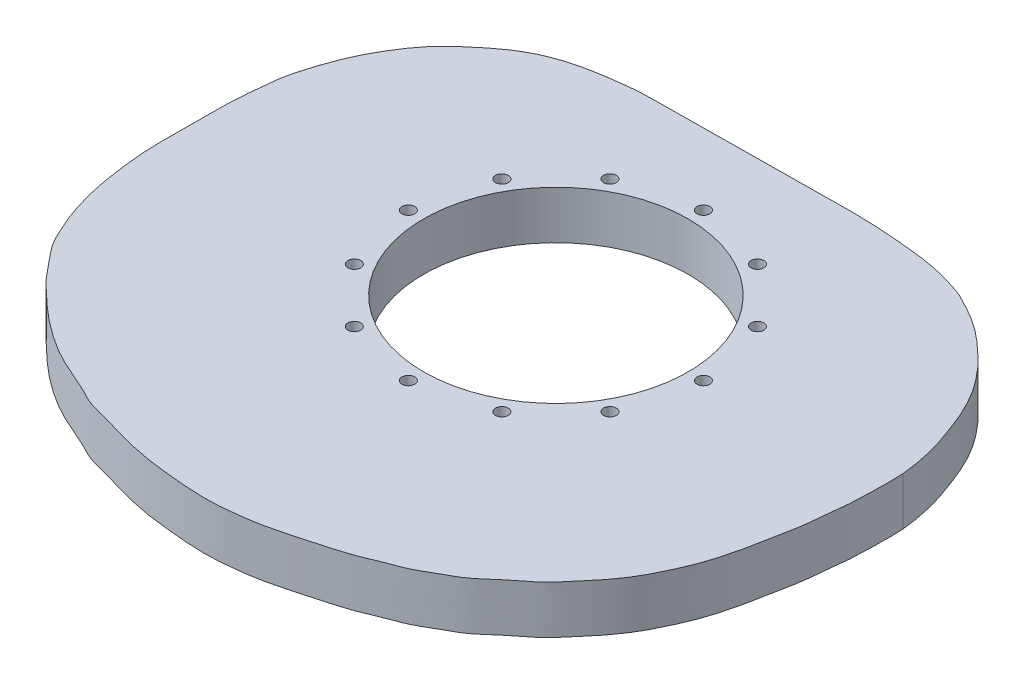
from build123d import *

# Parameters (mm, degrees)
SKETCH1_R               = 70.0278
BOSS_EXTRUDE1_DEPTH     = 25.4
F_1_4_CLEARANCE_HOLE2_D = 6.7564


with BuildPart() as part:
    # Sketch1 → Boss-Extrude1 (new body)
    with BuildSketch(Plane.XZ.offset(5)):
        with BuildLine():
            add(Edge.make_bspline(
                [(-380.049242402, 11.384506124), (-380.351727709, 7.622790631), (-381.694235545, -0.755231418), (-384.446209251, -11.663714484), (-388.103085236, -21.392143302), (-391.925650274, -31.575766127), (-398.295486923, -43.924651464), (-407.128882868, -55.651987185), (-416.38233598, -64.721478176), (-428.702675028, -75.720010967), (-441.765278826, -82.662991669), (-448.736085978, -86.474565006), (-459.378159259, -89.383248937), (-468.639960146, -91.8901143), (-483.883064645, -93.531241417), (-505.293765442, -95.360493014), (-537.935613256, -94.80996853), (-620.863987688, -94.064878486), (-625.28981964, -93.74269195), (-632.616728819, -93.108667889), (-643.969557151, -91.505035169), (-654.698440304, -89.313581428), (-665.553686296, -85.820433064), (-677.5449018, -79.679626513), (-689.821764124, -69.789276702), (-700.818947164, -59.846392143), (-709.719423576, -47.179017), (-717.454447417, -32.860897599), (-722.916833642, -16.936482122), (-725.870843695, -5.469698769), (-726.432591043, 2.747731753), (-728.061402677, 15.952356205), (-728.016636304, 29.622005318), (-728.183208156, 51.378488644), (-728.21049183, 66.165802061), (-725.016148135, 91.652991888), (-719.307424347, 111.760000031), (-715.0325054, 120.938944975), (-713.402971141, 124.355557991)],
                knots=[0.50544859, 0.50544859, 0.50544859, 0.50544859, 0.517878892, 0.529901202, 0.541289027, 0.552999913, 0.566304447, 0.57990339, 0.592750982, 0.607327706, 0.620921089, 0.630996152, 0.642558345, 0.653666263, 0.667424603, 0.6832709, 0.705284101, 0.73716196, 0.744619627, 0.753696597, 0.765929643, 0.777787395, 0.789712766, 0.802766477, 0.816920196, 0.830645044, 0.844557861, 0.859020432, 0.873719976, 0.885805087, 0.895975767, 0.908692411, 0.922195793, 0.938566323, 0.952559431, 0.970498516, 0.987057969, 1, 1, 1, 1], degree=3))
            add(Edge.make_bspline(
                [(-713.402971141, 124.355557991), (-712.082084168, 127.125036205), (-709.617350154, 132.160552397), (-702.170293732, 140.542517459), (-695.525171462, 149.350196139), (-687.223081889, 156.809984363), (-678.206935924, 165.478516531), (-664.382461732, 175.574467603), (-651.593849459, 182.9115829), (-634.095803666, 189.897384063), (-627.718557894, 194.173130242), (-612.113684776, 197.577423723), (-603.130207723, 200.783493104), (-587.87816061, 204.27385061), (-575.41843016, 205.66216801), (-564.404831801, 206.832438516), (-549.976053816, 207.428175425), (-539.569701315, 206.291002113), (-527.522968626, 204.922987531), (-512.585939787, 201.034632879), (-500.806129361, 197.778091631), (-485.928212709, 193.471241405), (-475.470893595, 188.514516299), (-466.6221847, 185.765786858), (-457.127275413, 179.763339122), (-449.285579073, 175.925612235), (-442.200673858, 170.296384682), (-434.141792994, 162.772660136), (-425.254220573, 156.65946043), (-418.752029856, 148.539162308), (-410.4939809, 139.328454671), (-403.000646081, 128.490795573), (-397.621768075, 117.696417735), (-392.042287791, 104.805455109), (-388.923669, 93.12362208), (-386.85424183, 84.123556824), (-385.100288246, 73.57048821), (-383.498849059, 66.21506186), (-382.239451768, 58.916781907), (-381.935896416, 51.434929715), (-380.478735134, 42.128572628), (-379.978179166, 32.508189516), (-379.846191862, 20.901313704), (-379.780162952, 14.730785467), (-380.049242402, 11.384506124)],
                knots=[0, 0, 0, 0, 0.010490703, 0.022302646, 0.034197509, 0.045974038, 0.058625769, 0.073218581, 0.087340405, 0.10244368, 0.112613745, 0.126406556, 0.137824072, 0.151733222, 0.164417966, 0.176313746, 0.189761229, 0.201308267, 0.213677656, 0.227608415, 0.240254901, 0.254220816, 0.266329099, 0.277135379, 0.288992631, 0.299528683, 0.310153006, 0.322011099, 0.333676434, 0.345096137, 0.35764689, 0.370545352, 0.382962849, 0.396338867, 0.408685878, 0.419575584, 0.431148405, 0.440987376, 0.450542287, 0.460302127, 0.471162024, 0.482341786, 0.494391065, 0.50544859, 0.50544859, 0.50544859, 0.50544859], degree=3))
        make_face()
        with Locations((-553.414580293, 21.431048711)):
            Circle(SKETCH1_R, mode=Mode.SUBTRACT)
    extrude(amount=-BOSS_EXTRUDE1_DEPTH)

    # 1/4 Clearance Hole2 (through all)
    with Locations(Plane(origin=(0, -5, 0), x_dir=(-1, 0, 0), z_dir=(0, -1, 0))):
        with Locations((592.428480293, -89.005105712), (620.988637295, -60.444948711), (631.442380293, -21.431048711), (620.988637295, 17.582851289), (592.428480293, 46.143008291), (553.414580293, 56.596751289), (514.400680293, 46.143008291), (485.840523292, 17.582851289), (475.386780293, -21.431048711), (485.840523292, -60.444948711), (514.400680293, -89.005105712), (553.414580293, -99.458848711)):
            Hole(F_1_4_CLEARANCE_HOLE2_D / 2)


solid = part.part
